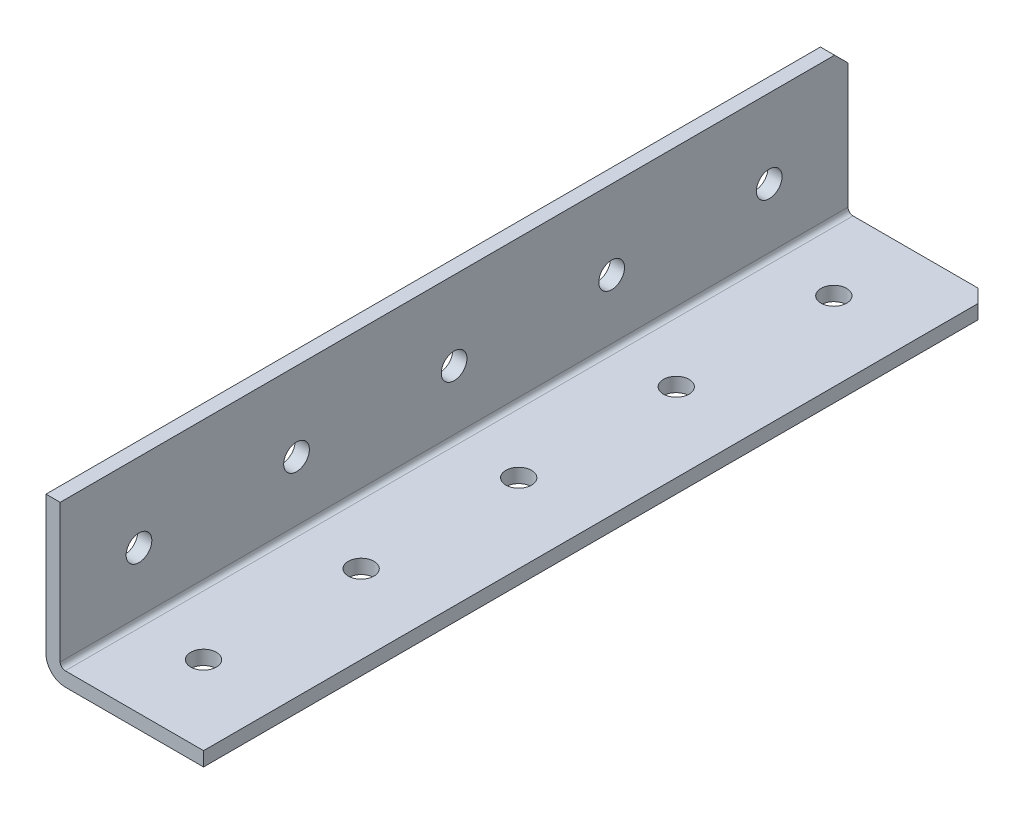
from build123d import *

# Parameters (mm, degrees)
SKETCH1_W                  = 25.4
SKETCH1_H                  = 1498.6
BOSS_EXTRUDE1_DEPTH        = 25.4
SKETCH2_W                  = 23.114
SKETCH2_H                  = 23.114
CUT_EXTRUDE1_DEPTH         = 1499.6
M3_5_CLEARANCE_HOLE1_D     = 4.1402
M3_5_CLEARANCE_HOLE1_DEPTH = 25.4
M3_5_CLEARANCE_HOLE2_D     = 4.1402
M3_5_CLEARANCE_HOLE2_DEPTH = 25.4
CHAMFER1_SIZE              = 2.159
FILLET1_R                  = 0.8128
FILLET2_R                  = 3.0988
SKETCH8_W                  = 95.882963774
SKETCH8_H                  = 79.338329604
CUT_EXTRUDE3_DEPTH         = 1371.6


with BuildPart() as part:
    # Sketch1 → Boss-Extrude1 (new body)
    with BuildSketch(Plane(origin=(0, 0, 0), x_dir=(0, -1, 0), z_dir=(-1, 0, 0))):
        with Locations((-12.7, 0)):
            Rectangle(SKETCH1_W, SKETCH1_H)
    extrude(amount=-BOSS_EXTRUDE1_DEPTH)

    # Sketch2 → Cut-Extrude1 (cut, through all)
    with BuildSketch(Plane(origin=(0, 0, -749.3), x_dir=(-1, 0, 0), z_dir=(0, 0, -1))):
        with Locations((-13.843, 13.843)):
            Rectangle(SKETCH2_W, SKETCH2_H)
    extrude(amount=-CUT_EXTRUDE1_DEPTH, mode=Mode.SUBTRACT)

    # M3.5 Clearance Hole1
    with Locations(Plane(origin=(0, 0, 0), x_dir=(-1, 0, 0), z_dir=(0, -1, 0))):
        with Locations((-12.7, 736.6), (-12.7, 711.2), (-12.7, 685.8), (-12.7, 660.4), (-12.7, 635), (-12.7, 609.6), (-12.7, 584.2), (-12.7, 558.8), (-12.7, 533.4), (-12.7, 508), (-12.7, 482.6), (-12.7, 457.2), (-12.7, 431.8), (-12.7, 406.4), (-12.7, 381), (-12.7, 355.6), (-12.7, 330.2), (-12.7, 304.8), (-12.7, 279.4), (-12.7, 254), (-12.7, 228.6), (-12.7, 203.2), (-12.7, 177.8), (-12.7, 152.4), (-12.7, 127), (-12.7, 101.6), (-12.7, 76.2), (-12.7, 50.8), (-12.7, 25.4), (-12.7, 0), (-12.7, -25.4), (-12.7, -50.8), (-12.7, -76.2), (-12.7, -101.6), (-12.7, -127), (-12.7, -152.4), (-12.7, -177.8), (-12.7, -203.2), (-12.7, -228.6), (-12.7, -254), (-12.7, -279.4), (-12.7, -304.8), (-12.7, -330.2), (-12.7, -355.6), (-12.7, -381), (-12.7, -406.4), (-12.7, -431.8), (-12.7, -457.2), (-12.7, -482.6), (-12.7, -508), (-12.7, -533.4), (-12.7, -558.8), (-12.7, -584.2), (-12.7, -609.6), (-12.7, -635), (-12.7, -660.4), (-12.7, -685.8), (-12.7, -711.2), (-12.7, -736.6)):
            Hole(M3_5_CLEARANCE_HOLE1_D / 2, depth=M3_5_CLEARANCE_HOLE1_DEPTH)

    # M3.5 Clearance Hole2
    with Locations(Plane.ZY):
        with Locations((711.2, 12.7), (736.6, 12.7), (685.8, 12.7), (660.4, 12.7), (635, 12.7), (609.6, 12.7), (584.2, 12.7), (558.8, 12.7), (533.4, 12.7), (508, 12.7), (482.6, 12.7), (457.2, 12.7), (431.8, 12.7), (406.4, 12.7), (381, 12.7), (355.6, 12.7), (330.2, 12.7), (304.8, 12.7), (279.4, 12.7), (254, 12.7), (228.6, 12.7), (203.2, 12.7), (177.8, 12.7), (152.4, 12.7), (127, 12.7), (101.6, 12.7), (76.2, 12.7), (50.8, 12.7), (25.4, 12.7), (0, 12.7), (-25.4, 12.7), (-50.8, 12.7), (-76.2, 12.7), (-101.6, 12.7), (-127, 12.7), (-152.4, 12.7), (-177.8, 12.7), (-203.2, 12.7), (-228.6, 12.7), (-254, 12.7), (-279.4, 12.7), (-304.8, 12.7), (-330.2, 12.7), (-355.6, 12.7), (-381, 12.7), (-406.4, 12.7), (-431.8, 12.7), (-457.2, 12.7), (-482.6, 12.7), (-508, 12.7), (-533.4, 12.7), (-558.8, 12.7), (-584.2, 12.7), (-609.6, 12.7), (-635, 12.7), (-660.4, 12.7), (-685.8, 12.7), (-711.2, 12.7), (-736.6, 12.7)):
            Hole(M3_5_CLEARANCE_HOLE2_D / 2, depth=M3_5_CLEARANCE_HOLE2_DEPTH)

    # Chamfer1
    chamfer1_edges = [part.edges().sort_by_distance(p)[0] for p in [
        (25.4, 1.143, -749.3),
        (1.143, 25.4, 749.3),
        (1.143, 25.4, -749.3),
        (25.4, 1.143, 749.3),
    ]]
    chamfer(chamfer1_edges, length=CHAMFER1_SIZE)

    # Fillet1
    fillet1_edges = [part.edges().sort_by_distance(p)[0] for p in [
        (2.286, 2.286, 0),
    ]]
    fillet(fillet1_edges, radius=FILLET1_R)

    # Fillet2
    fillet2_edges = [part.edges().sort_by_distance(p)[0] for p in [
        (0, 0, 0),
    ]]
    fillet(fillet2_edges, radius=FILLET2_R)

    # Sketch8 → Cut-Extrude3 (cut)
    with BuildSketch(Plane.XY.offset(749.3)):
        with Locations((2.286, 3.0988)):
            Rectangle(SKETCH8_W, SKETCH8_H)
    extrude(amount=-CUT_EXTRUDE3_DEPTH, mode=Mode.SUBTRACT)


solid = part.part
